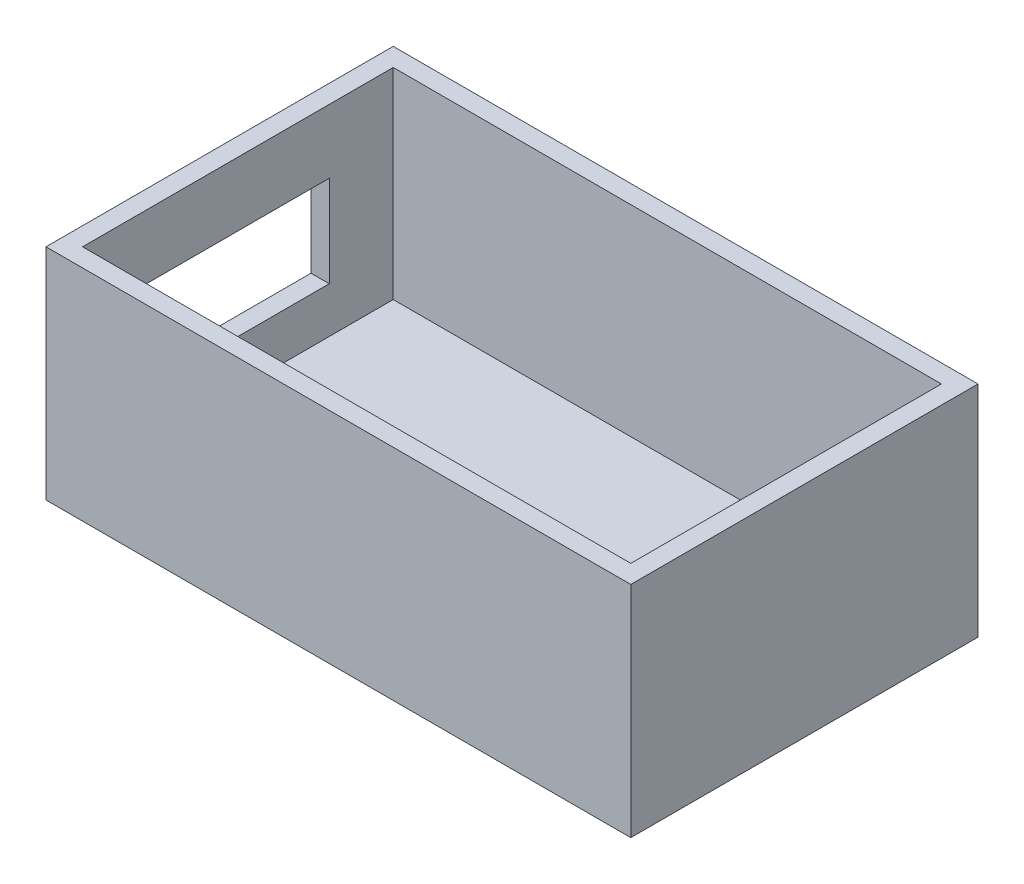
from build123d import *

# Parameters (mm, degrees)
CROQUIS1_W              = 32
CROQUIS1_H              = 19
CROQUIS1_W_2            = 30
CROQUIS1_H_2            = 17
SALIENTE_EXTRUIR1_DEPTH = 12
CROQUIS1_3_W            = 30
CROQUIS1_3_H            = 17
SALIENTE_EXTRUIR2_DEPTH = 1
CROQUIS2_W              = 10
CROQUIS2_H              = 5
CORTAR_EXTRUIR1_DEPTH   = 1


with BuildPart() as part:
    # Croquis1 → Saliente-Extruir1 (new body)
    with BuildSketch(Plane(origin=(0, 0, 0), x_dir=(1, 0, 0), z_dir=(0, 1, 0))):
        with Locations((15, 8.5)):
            Rectangle(CROQUIS1_W, CROQUIS1_H)
        with Locations((15, 8.5)):
            Rectangle(CROQUIS1_W_2, CROQUIS1_H_2, mode=Mode.SUBTRACT)
    extrude(amount=SALIENTE_EXTRUIR1_DEPTH)

    # Croquis1_3 → Saliente-Extruir2 (add)
    with BuildSketch(Plane(origin=(0, 0, 0), x_dir=(1, 0, 0), z_dir=(0, 1, 0))):
        with Locations((15, 8.5)):
            Rectangle(CROQUIS1_3_W, CROQUIS1_3_H)
    extrude(amount=SALIENTE_EXTRUIR2_DEPTH)

    # Croquis2 → Cortar-Extruir1 (cut)
    with BuildSketch(Plane.ZY.offset(1)):
        with Locations((-8.5, 6)):
            Rectangle(CROQUIS2_W, CROQUIS2_H)
    extrude(amount=-CORTAR_EXTRUIR1_DEPTH, mode=Mode.SUBTRACT)


solid = part.part
